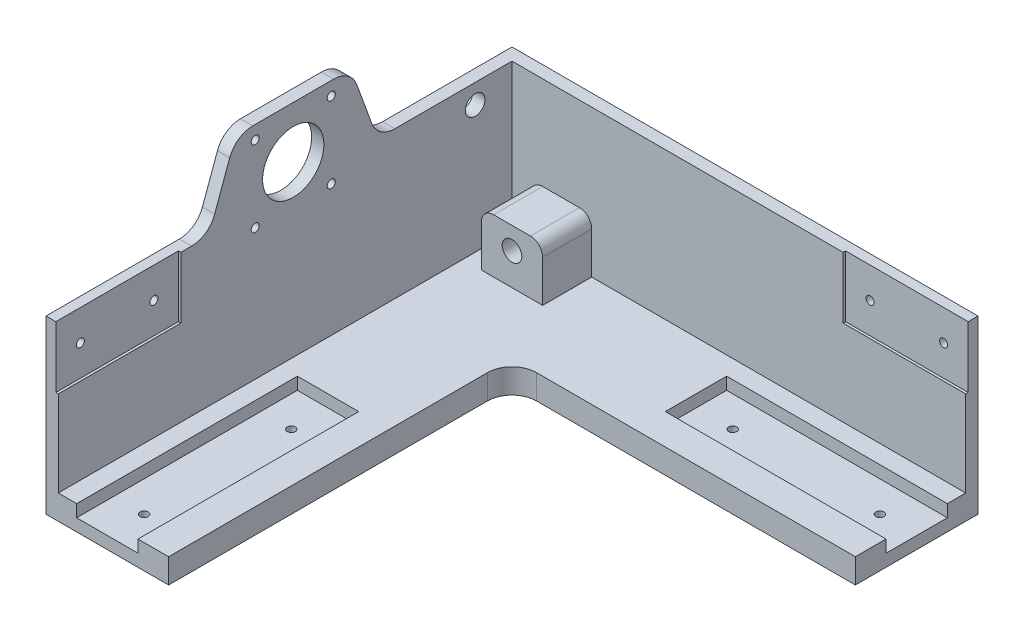
from build123d import *

# Parameters (mm, degrees)
BOSS_EXTRUDE1_DEPTH = 10
SKETCH2_W           = 90
SKETCH2_H           = 25
SKETCH2_W_2         = 25
SKETCH2_H_2         = 90
CUT_EXTRUDE1_DEPTH  = 5
SKETCH3_R           = 1.65
CUT_EXTRUDE2_DEPTH  = 6
SKETCH4_W           = 25
SKETCH4_H           = 25
BOSS_EXTRUDE2_DEPTH = 22
SKETCH5_R           = 4
CUT_EXTRUDE3_DEPTH  = 191
FILLET1_R           = 5
SKETCH6_W           = 190
SKETCH6_H           = 90
BOSS_EXTRUDE3_DEPTH = 5
SKETCH7_R           = 4
SKETCH7_R_2         = 12.5
SKETCH7_R_3         = 1.65
CUT_EXTRUDE4_DEPTH  = 6
SKETCH8_W           = 185
SKETCH8_H           = 5
BOSS_EXTRUDE4_DEPTH = 60
SKETCH9_R           = 4
CUT_EXTRUDE5_DEPTH  = 191
CUT_EXTRUDE6_DEPTH  = 6
FILLET2_R           = 10
SKETCH11_W          = 50
SKETCH11_H          = 25
CUT_EXTRUDE7_DEPTH  = 1
SKETCH12_R          = 1.65
CUT_EXTRUDE8_DEPTH  = 5
SKETCH13_W          = 50
SKETCH13_H          = 25
CUT_EXTRUDE9_DEPTH  = 1
SKETCH14_R          = 1.65
CUT_EXTRUDE10_DEPTH = 5


with BuildPart() as part:
    # Sketch1 → Boss-Extrude1 (new body)
    with BuildSketch(Plane(origin=(0, 0, 0), x_dir=(1, 0, 0), z_dir=(0, 1, 0))):
        with BuildLine():
            Line((-59.092867484, 30.230027325), (130.907132516, 30.230027325))
            Line((130.907132516, 30.230027325), (130.907132516, -19.769972675))
            Line((130.907132516, -19.769972675), (0.907132516, -19.769972675))
            ThreePointArc((0.907132516, -19.769972675), (-6.163935296, -22.698904864), (-9.092867484, -29.769972675))
            Line((-9.092867484, -29.769972675), (-9.092867484, -159.769972675))
            Line((-9.092867484, -159.769972675), (-59.092867484, -159.769972675))
            Line((-59.092867484, -159.769972675), (-59.092867484, 30.230027325))
        make_face()
    extrude(amount=BOSS_EXTRUDE1_DEPTH)

    # Sketch2 → Cut-Extrude1 (cut)
    with BuildSketch(Plane(origin=(0, 10, 0), x_dir=(1, 0, 0), z_dir=(0, 1, 0))):
        with Locations((85.907132516, 5.230027325)):
            Rectangle(SKETCH2_W, SKETCH2_H)
        with Locations((-34.092867484, -114.769972675)):
            Rectangle(SKETCH2_W_2, SKETCH2_H_2)
    extrude(amount=-CUT_EXTRUDE1_DEPTH, mode=Mode.SUBTRACT)

    # Sketch3 → Cut-Extrude2 (cut, through all)
    with BuildSketch(Plane(origin=(0, 5, 0), x_dir=(1, 0, 0), z_dir=(0, 1, 0))):
        with Locations((55.907132516, 5.230027325)):
            Circle(SKETCH3_R)
        with Locations((115.907132516, 5.230027325)):
            Circle(SKETCH3_R)
        with Locations((-34.092867483, -84.769972675)):
            Circle(SKETCH3_R)
        with Locations((-34.092867483, -144.769972675)):
            Circle(SKETCH3_R)
    extrude(amount=-CUT_EXTRUDE2_DEPTH, mode=Mode.SUBTRACT)

    # Sketch4 → Boss-Extrude2 (add)
    with BuildSketch(Plane(origin=(0, 10, 0), x_dir=(1, 0, 0), z_dir=(0, 1, 0))):
        with Locations((-34.092867484, 17.730027325)):
            Rectangle(SKETCH4_W, SKETCH4_H)
    extrude(amount=BOSS_EXTRUDE2_DEPTH)

    # Sketch5 → Cut-Extrude3 (cut, through all)
    with BuildSketch(Plane(origin=(0, 0, -30.230027325), x_dir=(-1, 0, 0), z_dir=(0, 0, -1))):
        with Locations((34.092867484, 23)):
            Circle(SKETCH5_R)
    extrude(amount=-CUT_EXTRUDE3_DEPTH, mode=Mode.SUBTRACT)

    # Fillet1
    fillet1_edges = [part.edges().sort_by_distance(p)[0] for p in [
        (-46.592867484, 32, -17.730027325),
        (-21.592867484, 32, -17.730027325),
    ]]
    fillet(fillet1_edges, radius=FILLET1_R)

    # Sketch6 → Boss-Extrude3 (add)
    with BuildSketch(Plane.ZY.offset(59.092867484)):
        with Locations((64.769972675, 55)):
            Rectangle(SKETCH6_W, SKETCH6_H)
    extrude(amount=-BOSS_EXTRUDE3_DEPTH)

    # Sketch7 → Cut-Extrude4 (cut, through all)
    with BuildSketch(Plane(origin=(-54.092867484, 0, 0), x_dir=(0, 0, -1), z_dir=(1, 0, 0))):
        with Locations((10.230027325, 62)):
            Circle(SKETCH7_R)
        with Locations((-63.970957781, 79)):
            Circle(SKETCH7_R_2)
        with Locations((-79.470957781, 94.5)):
            Circle(SKETCH7_R_3)
        with Locations((-48.470957781, 94.5)):
            Circle(SKETCH7_R_3)
        with Locations((-48.470957781, 63.5)):
            Circle(SKETCH7_R_3)
        with Locations((-79.470957781, 63.5)):
            Circle(SKETCH7_R_3)
    extrude(amount=-CUT_EXTRUDE4_DEPTH, mode=Mode.SUBTRACT)

    # Sketch8 → Boss-Extrude4 (add)
    with BuildSketch(Plane(origin=(0, 10, 0), x_dir=(1, 0, 0), z_dir=(0, 1, 0))):
        with Locations((38.407132516, 27.730027325)):
            Rectangle(SKETCH8_W, SKETCH8_H)
    extrude(amount=BOSS_EXTRUDE4_DEPTH)

    # Sketch9 → Cut-Extrude5 (cut, through all)
    with BuildSketch(Plane(origin=(0, 0, -30.230027325), x_dir=(-1, 0, 0), z_dir=(0, 0, -1))):
        with Locations((34.092867484, 23)):
            Circle(SKETCH9_R)
    extrude(amount=-CUT_EXTRUDE5_DEPTH, mode=Mode.SUBTRACT)

    # Sketch10 → Cut-Extrude6 (cut, through all)
    with BuildSketch(Plane(origin=(-54.092867484, 0, 0), x_dir=(0, 0, -1), z_dir=(1, 0, 0))):
        Polygon((-159.769972675, 70), (-98.390064809, 70), (-87.470957781, 100), (-159.769972675, 100), align=None)
        Polygon((-40.470957781, 100), (-29.551850753, 70), (25.230027325, 70), (30.230027325, 70), (30.230027325, 100), align=None)
    extrude(amount=-CUT_EXTRUDE6_DEPTH, mode=Mode.SUBTRACT)

    # Fillet2
    fillet2_edges = [part.edges().sort_by_distance(p)[0] for p in [
        (-56.592867484, 100, 87.470957781),
        (-56.592867484, 70, 98.390064809),
        (-56.592867484, 100, 40.470957781),
        (-56.592867484, 70, 29.551850753),
    ]]
    fillet(fillet2_edges, radius=FILLET2_R)

    # Sketch11 → Cut-Extrude7 (cut)
    with BuildSketch(Plane.XY.offset(-25.230027325)):
        with Locations((105.907132516, 57.5)):
            Rectangle(SKETCH11_W, SKETCH11_H)
    extrude(amount=-CUT_EXTRUDE7_DEPTH, mode=Mode.SUBTRACT)

    # Sketch12 → Cut-Extrude8 (cut, through all)
    with BuildSketch(Plane.XY.offset(-26.230027325)):
        with Locations((90.907132516, 57.5)):
            Circle(SKETCH12_R)
        with Locations((120.907132516, 57.5)):
            Circle(SKETCH12_R)
    extrude(amount=-CUT_EXTRUDE8_DEPTH, mode=Mode.SUBTRACT)

    # Sketch13 → Cut-Extrude9 (cut)
    with BuildSketch(Plane(origin=(-54.092867484, 0, 0), x_dir=(0, 0, -1), z_dir=(1, 0, 0))):
        with Locations((-134.769972675, 57.5)):
            Rectangle(SKETCH13_W, SKETCH13_H)
    extrude(amount=-CUT_EXTRUDE9_DEPTH, mode=Mode.SUBTRACT)

    # Sketch14 → Cut-Extrude10 (cut, through all)
    with BuildSketch(Plane(origin=(-55.092867484, 0, 0), x_dir=(0, 0, -1), z_dir=(1, 0, 0))):
        with Locations((-149.769972675, 57.5)):
            Circle(SKETCH14_R)
        with Locations((-119.769972675, 57.5)):
            Circle(SKETCH14_R)
    extrude(amount=-CUT_EXTRUDE10_DEPTH, mode=Mode.SUBTRACT)


solid = part.part
